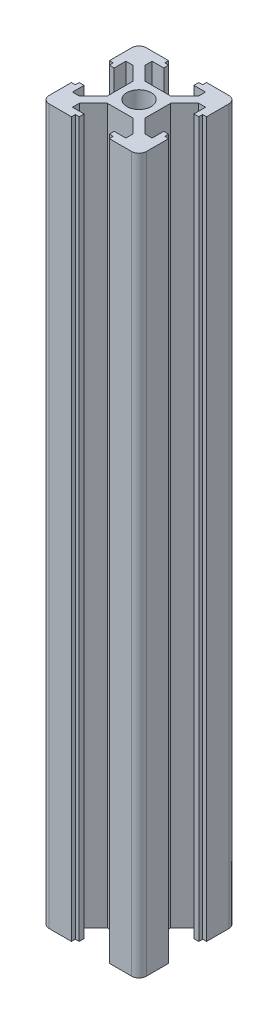
from build123d import *

# Parameters (mm, degrees)
SKETCH1_R           = 2.5
BOSS_EXTRUDE1_DEPTH = 147


with BuildPart() as part:
    # Sketch1 → Boss-Extrude1 (new body)
    with BuildSketch(Plane(origin=(0, 0, 0), x_dir=(1, 0, 0), z_dir=(0, 1, 0))):
        with BuildLine():
            Line((3.9, 10), (8.5, 10))
            ThreePointArc((8.5, 10), (9.560660172, 9.560660172), (10, 8.5))
            Line((10, 8.5), (10, 3.9))
            Line((10, 3.9), (9.2, 3.9))
            Line((9.2, 3.9), (9.2, 3.1))
            Line((9.2, 3.1), (8.2, 3.1))
            Line((8.2, 3.1), (8.2, 5.5))
            Line((8.2, 5.5), (6.77, 5.5))
            Line((6.77, 5.5), (3.9, 2.63))
            Line((3.9, 2.63), (3.9, 0))
            Line((3.9, 0), (3.9, -2.63))
            Line((3.9, -2.63), (6.77, -5.5))
            Line((6.77, -5.5), (8.2, -5.5))
            Line((8.2, -5.5), (8.2, -3.1))
            Line((8.2, -3.1), (9.2, -3.1))
            Line((9.2, -3.1), (9.2, -3.9))
            Line((9.2, -3.9), (10, -3.9))
            Line((10, -3.9), (10, -8.5))
            ThreePointArc((10, -8.5), (9.560660172, -9.560660172), (8.5, -10))
            Line((8.5, -10), (3.9, -10))
            Line((3.9, -10), (3.9, -9.2))
            Line((3.9, -9.2), (3.1, -9.2))
            Line((3.1, -9.2), (3.1, -8.2))
            Line((3.1, -8.2), (5.5, -8.2))
            Line((5.5, -8.2), (5.5, -6.77))
            Line((5.5, -6.77), (2.63, -3.9))
            Line((2.63, -3.9), (0, -3.9))
            Line((0, -3.9), (-2.63, -3.9))
            Line((-2.63, -3.9), (-5.5, -6.77))
            Line((-5.5, -6.77), (-5.5, -8.2))
            Line((-5.5, -8.2), (-3.1, -8.2))
            Line((-3.1, -8.2), (-3.1, -9.2))
            Line((-3.1, -9.2), (-3.9, -9.2))
            Line((-3.9, -9.2), (-3.9, -10))
            Line((-3.9, -10), (-8.5, -10))
            ThreePointArc((-8.5, -10), (-9.560660172, -9.560660172), (-10, -8.5))
            Line((-10, -8.5), (-10, -3.9))
            Line((-10, -3.9), (-9.2, -3.9))
            Line((-9.2, -3.9), (-9.2, -3.1))
            Line((-9.2, -3.1), (-8.2, -3.1))
            Line((-8.2, -3.1), (-8.2, -5.5))
            Line((-8.2, -5.5), (-6.77, -5.5))
            Line((-6.77, -5.5), (-3.9, -2.63))
            Line((-3.9, -2.63), (-3.9, 0))
            Line((-3.9, 0), (-3.9, 2.63))
            Line((-3.9, 2.63), (-6.77, 5.5))
            Line((-6.77, 5.5), (-8.2, 5.5))
            Line((-8.2, 5.5), (-8.2, 3.1))
            Line((-8.2, 3.1), (-9.2, 3.1))
            Line((-9.2, 3.1), (-9.2, 3.9))
            Line((-9.2, 3.9), (-10, 3.9))
            Line((-10, 3.9), (-10, 8.5))
            ThreePointArc((-10, 8.5), (-9.560660172, 9.560660172), (-8.5, 10))
            Line((-8.5, 10), (-3.9, 10))
            Line((-3.9, 10), (-3.9, 9.2))
            Line((-3.9, 9.2), (-3.1, 9.2))
            Line((-3.1, 9.2), (-3.1, 8.2))
            Line((-3.1, 8.2), (-5.5, 8.2))
            Line((-5.5, 8.2), (-5.5, 6.77))
            Line((-5.5, 6.77), (-2.63, 3.9))
            Line((-2.63, 3.9), (2.63, 3.9))
            Line((2.63, 3.9), (5.5, 6.77))
            Line((5.5, 6.77), (5.5, 8.2))
            Line((5.5, 8.2), (3.1, 8.2))
            Line((3.1, 8.2), (3.1, 9.2))
            Line((3.1, 9.2), (3.9, 9.2))
            Line((3.9, 9.2), (3.9, 10))
        make_face()
        Circle(SKETCH1_R, mode=Mode.SUBTRACT)
    extrude(amount=BOSS_EXTRUDE1_DEPTH)


solid = part.part
